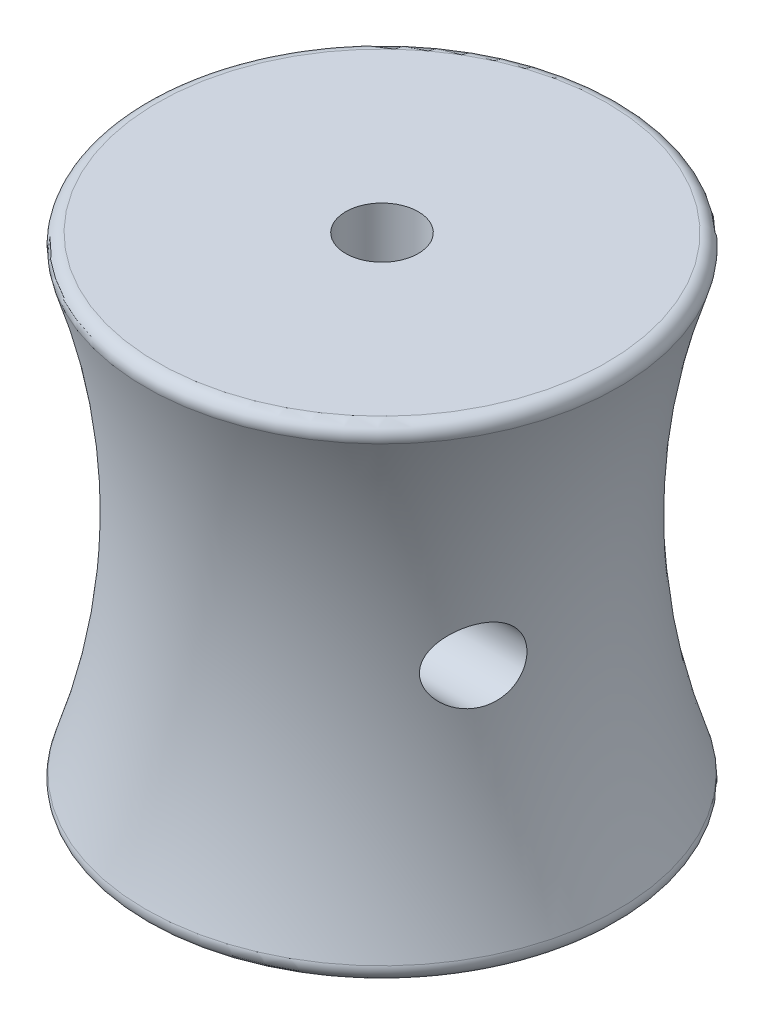
from build123d import *

# Parameters (mm, degrees)
CONG_1_R                     = 1
ESQUISSE2_R                  = 3
ENL_V_MAT_EXTRU_1_DEPTH      = 20.590364406
ENL_V_MAT_EXTRU_1_DEPTH_BACK = 20.590364406


with BuildPart() as part:
    # Esquisse1 → Révolution1 (revolve)
    with BuildSketch(Plane.XY):
        with BuildLine():
            Line((-3, 40), (-20, 40))
            ThreePointArc((-20, 40), (-16.476500446, 20), (-20, 0))
            Line((-20, 0), (-5, 0))
            Line((-5, 0), (-5, 7))
            Line((-5, 7), (-3, 7))
            Line((-3, 7), (-3, 40))
        make_face()
    revolve(axis=Axis((0, 0, 0), (0, 1, 0)))

    # Congé1
    cong_1_edges = [part.edges().sort_by_distance(p)[0] for p in [
        (20, 40, 0),
        (20, 0, 0),
    ]]
    fillet(cong_1_edges, radius=CONG_1_R)

    # Esquisse2 → Enlèv. mat.-Extru.1 (cut, two sides)
    with BuildSketch(Plane(origin=(0, 0, 0), x_dir=(0, 0, -1), z_dir=(1, 0, 0))) as enl_v_mat_extru_1_sk:
        with Locations((-7, 20)):
            Circle(ESQUISSE2_R)
    extrude(amount=ENL_V_MAT_EXTRU_1_DEPTH, mode=Mode.SUBTRACT)
    extrude(enl_v_mat_extru_1_sk.sketch, amount=-ENL_V_MAT_EXTRU_1_DEPTH_BACK, mode=Mode.SUBTRACT)


solid = part.part
